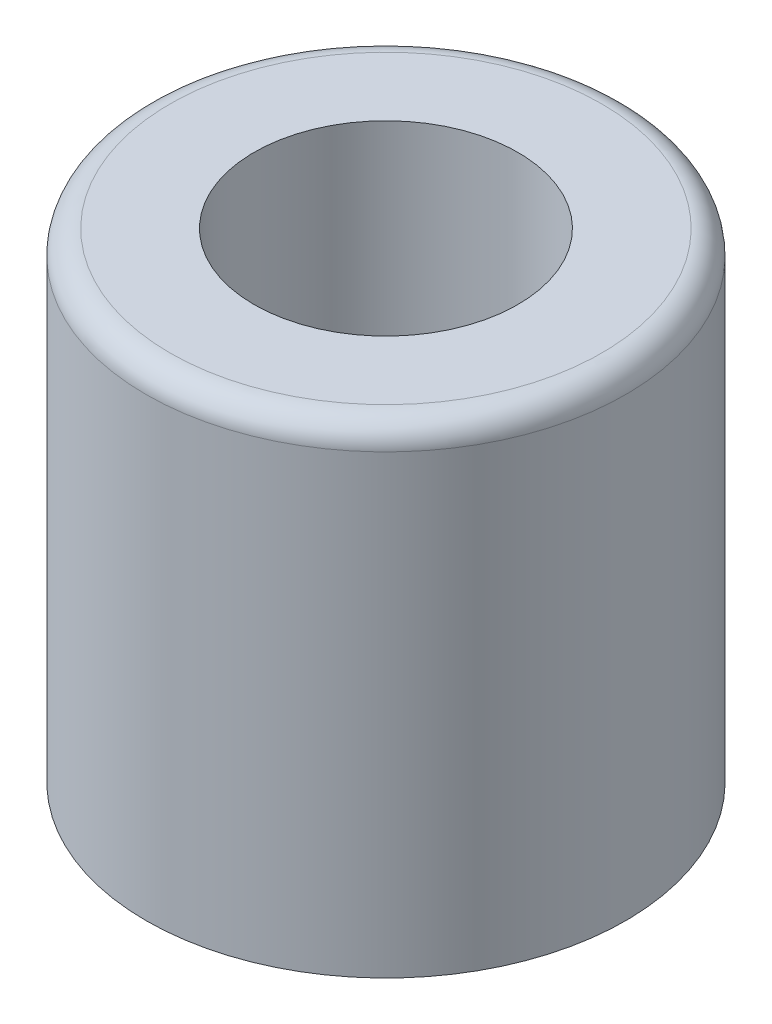
from build123d import *

# Parameters (mm, degrees)
SKETCH1_R           = 5
SKETCH1_R_2         = 2.75
BOSS_EXTRUDE1_DEPTH = 10
FILLET3_R           = 0.5


with BuildPart() as part:
    # Sketch1 → Boss-Extrude1 (new body)
    with BuildSketch(Plane(origin=(0, 0, 0), x_dir=(1, 0, 0), z_dir=(0, 1, 0))):
        Circle(SKETCH1_R)
        Circle(SKETCH1_R_2, mode=Mode.SUBTRACT)
    extrude(amount=BOSS_EXTRUDE1_DEPTH)

    # Fillet3
    fillet3_edges = [part.edges().sort_by_distance(p)[0] for p in [
        (-5, 10, 0),
    ]]
    fillet(fillet3_edges, radius=FILLET3_R)


solid = part.part
